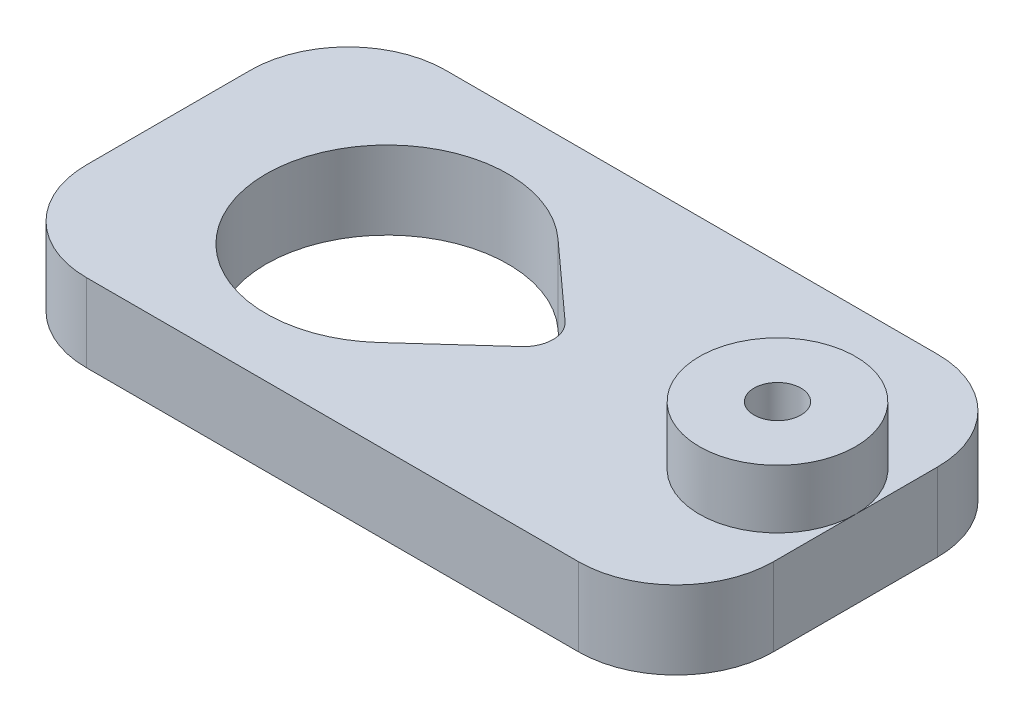
from build123d import *

# Parameters (mm, degrees)
SKETCH_1_W      = 5
SKETCH_1_H      = 12.4
SKETCH_1_R      = 1.2
EXTRUDE_1_DEPTH = 4
SKETCH_2_R      = 4
SKETCH_2_R_2    = 1.2
EXTRUDE_2_DEPTH = 3
FILLET_1_R      = 5


with BuildPart() as part:
    # Эскиз1 → Бобышка-Вытянуть1 (new body)
    with BuildSketch(Plane(origin=(0, 0, 0), x_dir=(1, 0, 0), z_dir=(0, 1, 0))):
        Polygon((-11.2, 6.2), (-6.2, 6.2), (0, 6.2), (16.4, 6.2), (21.4, 6.2), (21.4, -6.2), (16.4, -6.2), (6e-09, -6.2), (-6.2, -6.2), (-11.2, -6.2), (-11.2, -9.2), (24, -9.2), (24, 9.2), (-11.2, 9.2), align=None)
        Polygon((-6.2, 0), (-6.2, 6.2), (-11.2, 6.2), (-11.2, -6.2), (-6.2, -6.2), align=None)
        with Locations((18.9, 0)):
            Rectangle(SKETCH_1_W, SKETCH_1_H)
        with Locations((20, 0)):
            Circle(SKETCH_1_R, mode=Mode.SUBTRACT)
        with BuildLine():
            Line((16.4, 6.2), (0, 6.2))
            ThreePointArc((0, 6.2), (2.230840311, 5.784751637), (4.162857143, 4.594629518))
            Line((4.162857143, 4.594629518), (8.007142857, 1.111603916))
            ThreePointArc((8.007142857, 1.111603916), (8.37126115, 0.607982613), (8.5, 0))
            ThreePointArc((8.5, 0), (8.37126115, -0.607982613), (8.007142857, -1.111603916))
            Line((8.007142857, -1.111603916), (4.162857143, -4.594629518))
            ThreePointArc((4.162857143, -4.594629518), (2.230840314, -5.784751636), (6e-09, -6.2))
            Line((6e-09, -6.2), (16.4, -6.2))
            Line((16.4, -6.2), (16.4, 6.2))
        make_face()
        with BuildLine():
            Line((0, 6.2), (-6.2, 6.2))
            Line((-6.2, 6.2), (-6.2, 0))
            ThreePointArc((-6.2, 0), (-4.384062043, 4.384062043), (0, 6.2))
        make_face()
        with BuildLine():
            ThreePointArc((6e-09, -6.2), (-4.384062041, -4.384062046), (-6.2, 0))
            Line((-6.2, 0), (-6.2, -6.2))
            Line((-6.2, -6.2), (6e-09, -6.2))
        make_face()
    extrude(amount=EXTRUDE_1_DEPTH)

    # Эскиз2 → Бобышка-Вытянуть2 (add)
    with BuildSketch(Plane(origin=(0, 4, 0), x_dir=(1, 0, 0), z_dir=(0, 1, 0))):
        with Locations((20, 0)):
            Circle(SKETCH_2_R)
        with Locations((20, 0)):
            Circle(SKETCH_2_R_2, mode=Mode.SUBTRACT)
    extrude(amount=EXTRUDE_2_DEPTH)

    # Скругление1
    fillet_1_edges = [part.edges().sort_by_distance(p)[0] for p in [
        (24, 2, 9.2),
        (-11.2, 2, 9.2),
        (-11.2, 2, -9.2),
        (24, 2, -9.2),
    ]]
    fillet(fillet_1_edges, radius=FILLET_1_R)


solid = part.part
